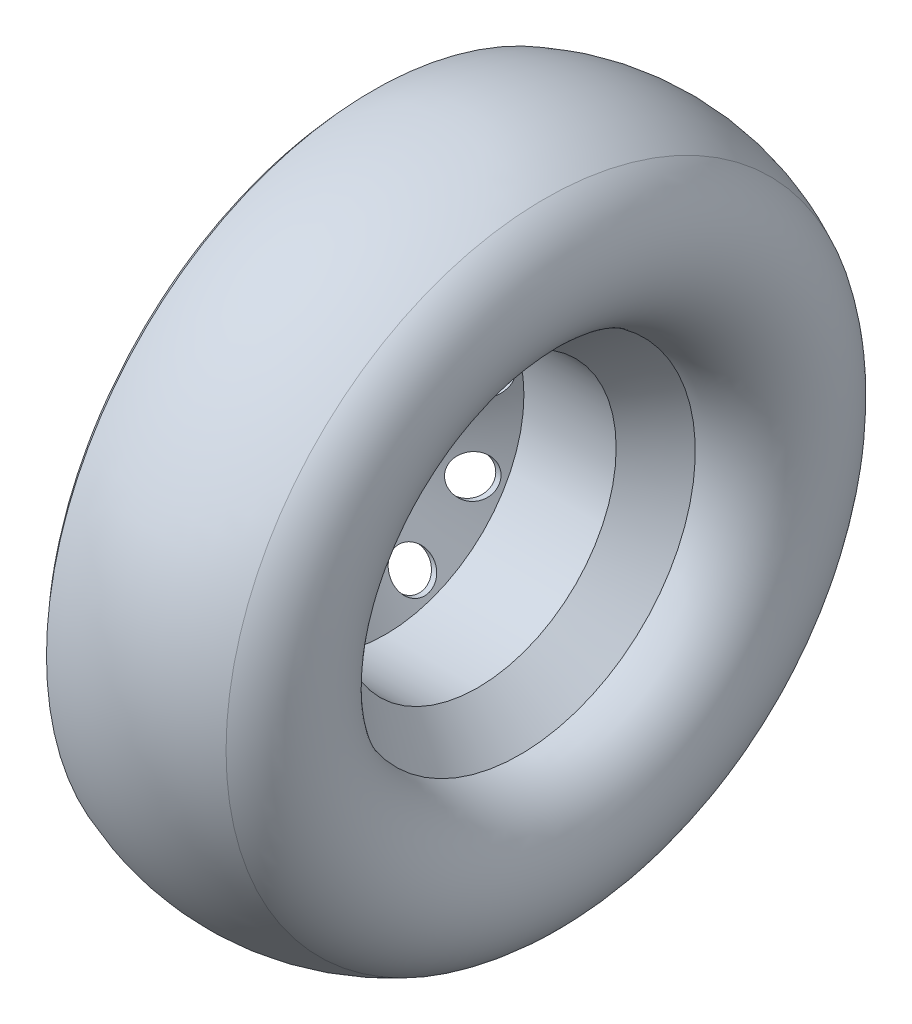
from build123d import *

# Parameters (mm, degrees)
SKETCH2_R          = 7.5
SKETCH2_R_2        = 17.5
CUT_EXTRUDE1_DEPTH = 221.470237338


with BuildPart() as part:
    # Sketch1 → Revolve4 (revolve)
    with BuildSketch(Plane.XY):
        with BuildLine():
            Line((35, 140), (0, 80))
            Line((0, 80), (0, 50))
            Line((0, 50), (5, 50))
            Line((5, 50), (5, 80))
            Line((5, 80), (35, 131.428571429))
            Line((35, 131.428571429), (122.587984779, 131.428571429))
            Line((122.587984779, 131.428571429), (162.587984779, 166.563614931))
            ThreePointArc((162.587984779, 166.563614931), (219.370145311, 226.785464126), (186.147014733, 302.595149983))
            ThreePointArc((186.147014733, 302.595149983), (105.375618176, 323.703614928), (23.023953154, 310))
            ThreePointArc((23.023953154, 310), (0.802810311, 254.210218216), (26.639435123, 200))
            Line((26.639435123, 200), (26.639435123, 160))
            Line((26.639435123, 160), (35, 140))
        make_face()
    revolve(axis=Axis((0, 0, 0), (1, 0, 0)))

    # Sketch2 → Cut-Extrude1 (cut, through all)
    with BuildSketch(Plane.ZY):
        with Locations((0, 60)):
            Circle(SKETCH2_R)
        with Locations((0, 110)):
            Circle(SKETCH2_R_2)
        with Locations((70.706637066, 84.264888743)):
            Circle(SKETCH2_R_2)
        with Locations((108.328852831, 19.101299543)):
            Circle(SKETCH2_R_2)
        with Locations((95.262794416, -55)):
            Circle(SKETCH2_R_2)
        with Locations((37.622215766, -103.366188286)):
            Circle(SKETCH2_R_2)
        with Locations((-37.622215766, -103.366188286)):
            Circle(SKETCH2_R_2)
        with Locations((-95.262794416, -55)):
            Circle(SKETCH2_R_2)
        with Locations((-108.328852831, 19.101299543)):
            Circle(SKETCH2_R_2)
        with Locations((-70.706637066, 84.264888743)):
            Circle(SKETCH2_R_2)
        with Locations((46.909888948, 37.409388112)):
            Circle(SKETCH2_R)
        with Locations((58.495674731, -13.351256037)):
            Circle(SKETCH2_R)
        with Locations((26.033024347, -54.058132074)):
            Circle(SKETCH2_R)
        with Locations((-26.033024347, -54.058132074)):
            Circle(SKETCH2_R)
        with Locations((-58.495674731, -13.351256037)):
            Circle(SKETCH2_R)
        with Locations((-46.909888948, 37.409388112)):
            Circle(SKETCH2_R)
    extrude(amount=-CUT_EXTRUDE1_DEPTH, mode=Mode.SUBTRACT)


solid = part.part
